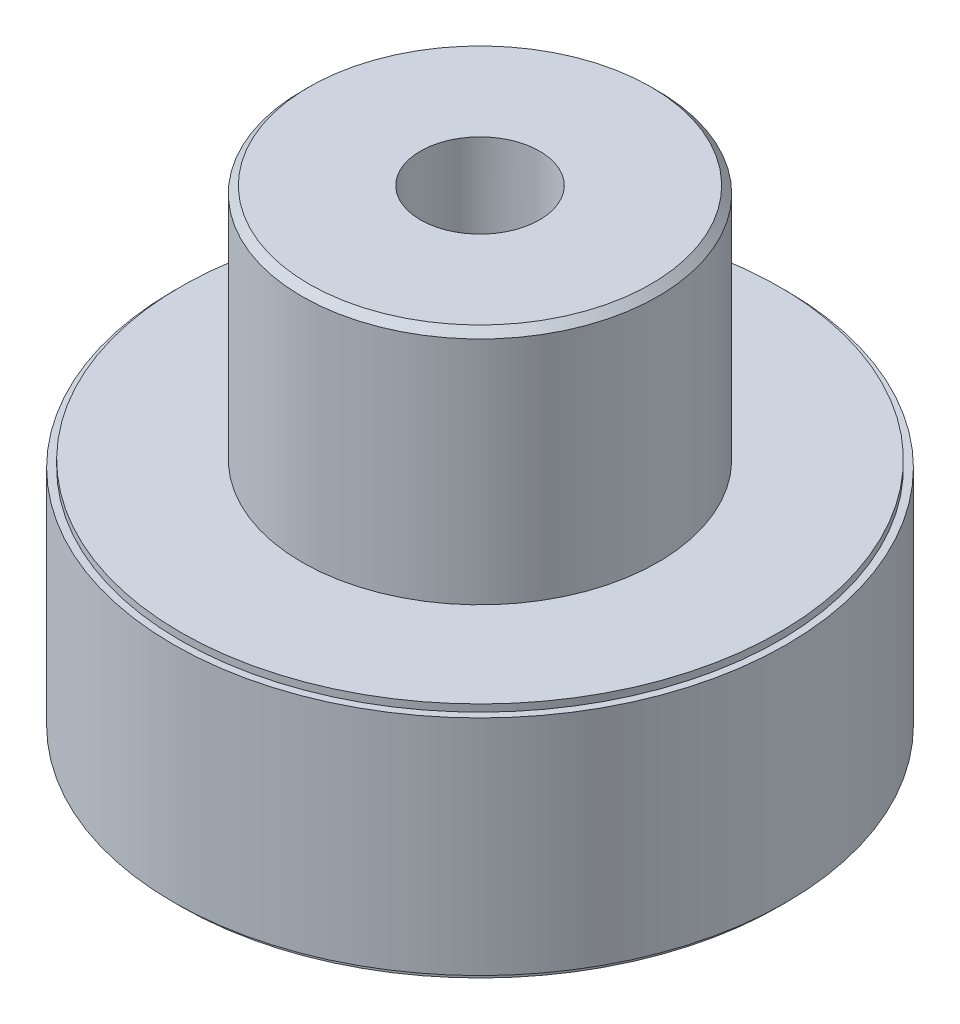
from build123d import *

# Parameters (mm, degrees)
SKETCH1_R           = 16.02
BOSS_EXTRUDE1_DEPTH = 0.38
SKETCH2_R           = 16.4
BOSS_EXTRUDE2_DEPTH = 11.94
SKETCH3_R           = 16.02
BOSS_EXTRUDE3_DEPTH = 0.38
SKETCH4_R           = 9.525
BOSS_EXTRUDE4_DEPTH = 12.32
SKETCH5_R           = 9.525
BOSS_EXTRUDE5_DEPTH = 0.38
BOSS_EXTRUDE5_TAPER = 45
SKETCH6_R           = 3.19
CUT_EXTRUDE1_DEPTH  = 19.05
SKETCH7_R           = 12.32
CUT_EXTRUDE5_DEPTH  = 0.38
CUT_EXTRUDE5_TAPER  = -45
SKETCH11_R          = 12.7
CUT_EXTRUDE6_DEPTH  = 5.97
SKETCH13_R          = 2.02
CUT_EXTRUDE7_DEPTH  = 10.97


with BuildPart() as part:
    # Sketch1 → Boss-Extrude1 (new body)
    with BuildSketch(Plane(origin=(0, 0, 0), x_dir=(1, 0, 0), z_dir=(0, 1, 0))):
        Circle(SKETCH1_R)
    extrude(amount=BOSS_EXTRUDE1_DEPTH)

    # Sketch2 → Boss-Extrude2 (add)
    with BuildSketch(Plane(origin=(0, 0.38, 0), x_dir=(1, 0, 0), z_dir=(0, 1, 0))):
        Circle(SKETCH2_R)
    extrude(amount=BOSS_EXTRUDE2_DEPTH)

    # Sketch3 → Boss-Extrude3 (add)
    with BuildSketch(Plane(origin=(0, 12.32, 0), x_dir=(1, 0, 0), z_dir=(0, 1, 0))):
        Circle(SKETCH3_R)
    extrude(amount=BOSS_EXTRUDE3_DEPTH)

    # Sketch4 → Boss-Extrude4 (add)
    with BuildSketch(Plane(origin=(0, 12.7, 0), x_dir=(1, 0, 0), z_dir=(0, 1, 0))):
        Circle(SKETCH4_R)
    extrude(amount=BOSS_EXTRUDE4_DEPTH)

    # Sketch5 → Boss-Extrude5 (add)
    with BuildSketch(Plane(origin=(0, 25.02, 0), x_dir=(1, 0, 0), z_dir=(0, 1, 0))):
        Circle(SKETCH5_R)
    extrude(amount=BOSS_EXTRUDE5_DEPTH, taper=BOSS_EXTRUDE5_TAPER)

    # Sketch6 → Cut-Extrude1 (cut)
    with BuildSketch(Plane(origin=(0, 25.4, 0), x_dir=(1, 0, 0), z_dir=(0, 1, 0))):
        Circle(SKETCH6_R)
    extrude(amount=-CUT_EXTRUDE1_DEPTH, mode=Mode.SUBTRACT)

    # Sketch7 → Cut-Extrude5 (cut)
    with BuildSketch(Plane(origin=(0, 6.35, 0), x_dir=(1, 0, 0), z_dir=(0, 1, 0))):
        Circle(SKETCH7_R)
    extrude(amount=-CUT_EXTRUDE5_DEPTH, taper=CUT_EXTRUDE5_TAPER, mode=Mode.SUBTRACT)

    # Sketch11 → Cut-Extrude6 (cut)
    with BuildSketch(Plane(origin=(0, 5.97, 0), x_dir=(1, 0, 0), z_dir=(0, 1, 0))):
        Circle(SKETCH11_R)
    extrude(amount=-CUT_EXTRUDE6_DEPTH, mode=Mode.SUBTRACT)

    # Sketch13 → Cut-Extrude7 (cut)
    with BuildSketch(Plane.XY):
        with Locations((0, 18.86)):
            Circle(SKETCH13_R)
    extrude(amount=-CUT_EXTRUDE7_DEPTH, mode=Mode.SUBTRACT)


solid = part.part
